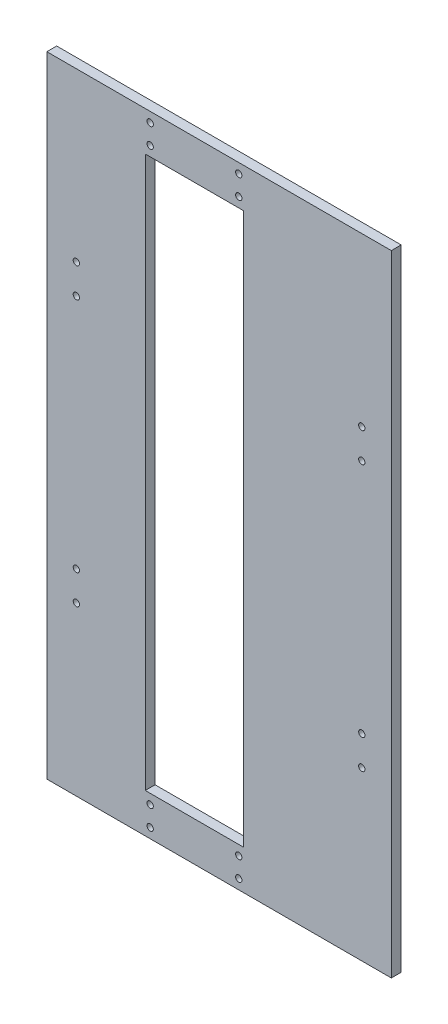
from build123d import *

# Parameters (mm, degrees)
SKETCH1_W           = 100
SKETCH1_H           = 320
SKETCH1_R           = 1.6
SKETCH1_W_2         = 50
SKETCH1_H_2         = 280
BOSS_EXTRUDE1_DEPTH = 5
SKETCH2_W           = 50
SKETCH2_H           = 320
BOSS_EXTRUDE2_DEPTH = 5
SKETCH3_W           = 25
SKETCH3_H           = 320
BOSS_EXTRUDE3_DEPTH = 5
CUT_EXTRUDE1_REACH  = 7
SKETCH4_R           = 1.6


with BuildPart() as part:
    # Sketch1 → Boss-Extrude1 (new body)
    with BuildSketch(Plane.XY):
        Rectangle(SKETCH1_W, SKETCH1_H)
        with Locations((-22.5, 145)):
            Circle(SKETCH1_R, mode=Mode.SUBTRACT)
        with Locations((-22.5, 155)):
            Circle(SKETCH1_R, mode=Mode.SUBTRACT)
        with Locations((22.5, 145)):
            Circle(SKETCH1_R, mode=Mode.SUBTRACT)
        with Locations((22.5, -145)):
            Circle(SKETCH1_R, mode=Mode.SUBTRACT)
        with Locations((-22.5, -145)):
            Circle(SKETCH1_R, mode=Mode.SUBTRACT)
        with Locations((22.5, 155)):
            Circle(SKETCH1_R, mode=Mode.SUBTRACT)
        with Locations((22.5, -155)):
            Circle(SKETCH1_R, mode=Mode.SUBTRACT)
        with Locations((-22.5, -155)):
            Circle(SKETCH1_R, mode=Mode.SUBTRACT)
        Rectangle(SKETCH1_W_2, SKETCH1_H_2, mode=Mode.SUBTRACT)
    extrude(amount=BOSS_EXTRUDE1_DEPTH)

    # Sketch2 → Boss-Extrude2 (add)
    with BuildSketch(Plane.XY):
        with Locations((75, 0)):
            Rectangle(SKETCH2_W, SKETCH2_H)
    extrude(amount=BOSS_EXTRUDE2_DEPTH)

    # Sketch3 → Boss-Extrude3 (add)
    with BuildSketch(Plane.XY):
        with Locations((-62.5, 0)):
            Rectangle(SKETCH3_W, SKETCH3_H)
    extrude(amount=BOSS_EXTRUDE3_DEPTH)

    # Sketch4 → Cut-Extrude1 (cut, up to next)
    with BuildSketch(Plane.XY.offset(5), mode=Mode.PRIVATE) as cut_extrude1_sk1:
        with Locations((-60, 75)):
            Circle(SKETCH4_R)
    cut_extrude1_tool1 = extrude(cut_extrude1_sk1.sketch, amount=-CUT_EXTRUDE1_REACH, mode=Mode.PRIVATE) & part.part
    add(cut_extrude1_tool1.solids().sort_by_distance((-60, 75, 5))[0], mode=Mode.SUBTRACT)
    # Sketch4 → Cut-Extrude1 (cut, up to next)
    with BuildSketch(Plane.XY.offset(5), mode=Mode.PRIVATE) as cut_extrude1_sk2:
        with Locations((-60, 60)):
            Circle(SKETCH4_R)
    cut_extrude1_tool2 = extrude(cut_extrude1_sk2.sketch, amount=-CUT_EXTRUDE1_REACH, mode=Mode.PRIVATE) & part.part
    add(cut_extrude1_tool2.solids().sort_by_distance((-60, 60, 5))[0], mode=Mode.SUBTRACT)
    # Sketch4 → Cut-Extrude1 (cut, up to next)
    with BuildSketch(Plane.XY.offset(5), mode=Mode.PRIVATE) as cut_extrude1_sk3:
        with Locations((-60, -60)):
            Circle(SKETCH4_R)
    cut_extrude1_tool3 = extrude(cut_extrude1_sk3.sketch, amount=-CUT_EXTRUDE1_REACH, mode=Mode.PRIVATE) & part.part
    add(cut_extrude1_tool3.solids().sort_by_distance((-60, -60, 5))[0], mode=Mode.SUBTRACT)
    # Sketch4 → Cut-Extrude1 (cut, up to next)
    with BuildSketch(Plane.XY.offset(5), mode=Mode.PRIVATE) as cut_extrude1_sk4:
        with Locations((-60, -75)):
            Circle(SKETCH4_R)
    cut_extrude1_tool4 = extrude(cut_extrude1_sk4.sketch, amount=-CUT_EXTRUDE1_REACH, mode=Mode.PRIVATE) & part.part
    add(cut_extrude1_tool4.solids().sort_by_distance((-60, -75, 5))[0], mode=Mode.SUBTRACT)
    # Sketch4 → Cut-Extrude1 (cut, up to next)
    with BuildSketch(Plane.XY.offset(5), mode=Mode.PRIVATE) as cut_extrude1_sk5:
        with Locations((85, -75)):
            Circle(SKETCH4_R)
    cut_extrude1_tool5 = extrude(cut_extrude1_sk5.sketch, amount=-CUT_EXTRUDE1_REACH, mode=Mode.PRIVATE) & part.part
    add(cut_extrude1_tool5.solids().sort_by_distance((85, -75, 5))[0], mode=Mode.SUBTRACT)
    # Sketch4 → Cut-Extrude1 (cut, up to next)
    with BuildSketch(Plane.XY.offset(5), mode=Mode.PRIVATE) as cut_extrude1_sk6:
        with Locations((85, -60)):
            Circle(SKETCH4_R)
    cut_extrude1_tool6 = extrude(cut_extrude1_sk6.sketch, amount=-CUT_EXTRUDE1_REACH, mode=Mode.PRIVATE) & part.part
    add(cut_extrude1_tool6.solids().sort_by_distance((85, -60, 5))[0], mode=Mode.SUBTRACT)
    # Sketch4 → Cut-Extrude1 (cut, up to next)
    with BuildSketch(Plane.XY.offset(5), mode=Mode.PRIVATE) as cut_extrude1_sk7:
        with Locations((85, 60)):
            Circle(SKETCH4_R)
    cut_extrude1_tool7 = extrude(cut_extrude1_sk7.sketch, amount=-CUT_EXTRUDE1_REACH, mode=Mode.PRIVATE) & part.part
    add(cut_extrude1_tool7.solids().sort_by_distance((85, 60, 5))[0], mode=Mode.SUBTRACT)
    # Sketch4 → Cut-Extrude1 (cut, up to next)
    with BuildSketch(Plane.XY.offset(5), mode=Mode.PRIVATE) as cut_extrude1_sk8:
        with Locations((85, 75)):
            Circle(SKETCH4_R)
    cut_extrude1_tool8 = extrude(cut_extrude1_sk8.sketch, amount=-CUT_EXTRUDE1_REACH, mode=Mode.PRIVATE) & part.part
    add(cut_extrude1_tool8.solids().sort_by_distance((85, 75, 5))[0], mode=Mode.SUBTRACT)


solid = part.part
